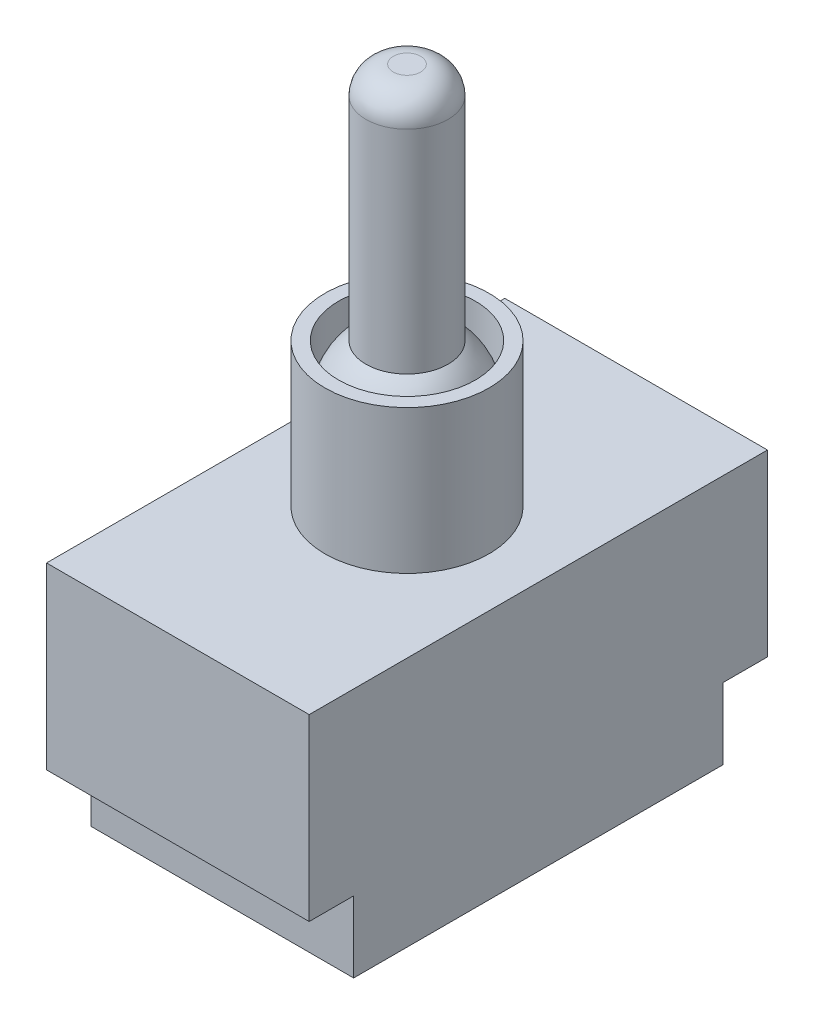
from build123d import *

# Parameters (mm, degrees)
SKETCH1_W           = 19.2
SKETCH1_H           = 33.5
BOSS_EXTRUDE1_DEPTH = 13.1
SKETCH2_R           = 6
BOSS_EXTRUDE2_DEPTH = 10.5
SKETCH4_R           = 5
CUT_EXTRUDE1_DEPTH  = 4
SKETCH5_R           = 3
BOSS_EXTRUDE3_DEPTH = 21.5
REVOLVE2_ANGLE      = 180
FILLET1_R           = 2
SKETCH6_W           = 19.2
SKETCH6_H           = 27
BOSS_EXTRUDE4_DEPTH = 5.2


with BuildPart() as part:
    # Sketch1 → Boss-Extrude1 (new body)
    with BuildSketch(Plane(origin=(0, 0, 0), x_dir=(1, 0, 0), z_dir=(0, 1, 0))):
        Rectangle(SKETCH1_W, SKETCH1_H)
    extrude(amount=BOSS_EXTRUDE1_DEPTH)

    # Sketch2 → Boss-Extrude2 (add)
    with BuildSketch(Plane(origin=(0, 13.1, 0), x_dir=(1, 0, 0), z_dir=(0, 1, 0))):
        Circle(SKETCH2_R)
    extrude(amount=BOSS_EXTRUDE2_DEPTH)

    # Sketch4 → Cut-Extrude1 (cut)
    with BuildSketch(Plane(origin=(0, 23.6, 0), x_dir=(1, 0, 0), z_dir=(0, 1, 0))):
        Circle(SKETCH4_R)
    extrude(amount=-CUT_EXTRUDE1_DEPTH, mode=Mode.SUBTRACT)

    # Sketch5 → Boss-Extrude3 (add)
    with BuildSketch(Plane(origin=(0, 19.6, 0), x_dir=(1, 0, 0), z_dir=(0, 1, 0))):
        Circle(SKETCH5_R)
    extrude(amount=BOSS_EXTRUDE3_DEPTH)

    # Sketch3 → Revolve2 (revolve)
    with BuildSketch(Plane(origin=(0, 19.6, 0), x_dir=(1, 0, 0), z_dir=(0, 1, 0))):
        with BuildLine():
            Line((0, -5), (0, 5))
            ThreePointArc((0, 5), (-5, 0), (0, -5))
        make_face()
    revolve(axis=Axis((0, 19.6, 6), (0, 0, -1)), revolution_arc=REVOLVE2_ANGLE)

    # Fillet1
    fillet1_edges = [part.edges().sort_by_distance(p)[0] for p in [
        (-3, 41.1, 0),
    ]]
    fillet(fillet1_edges, radius=FILLET1_R)

    # Sketch6 → Boss-Extrude4 (add)
    with BuildSketch(Plane.XZ):
        Rectangle(SKETCH6_W, SKETCH6_H)
    extrude(amount=BOSS_EXTRUDE4_DEPTH)


solid = part.part
